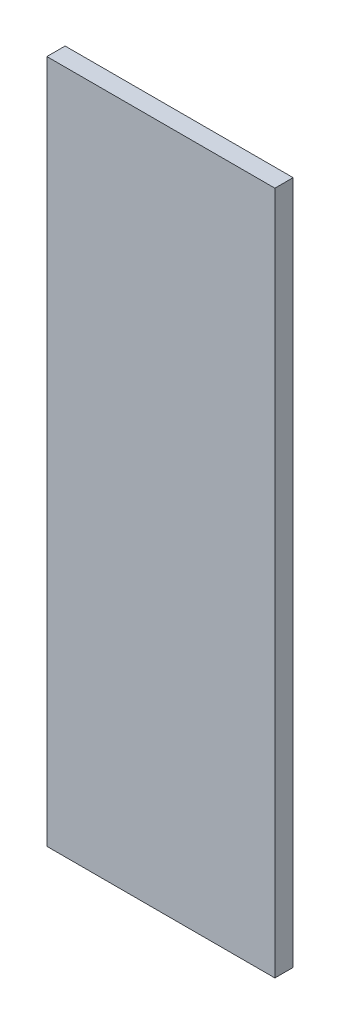
from build123d import *

# Parameters (mm, degrees)
SKETCH1_W           = 50
SKETCH1_H           = 150
BOSS_EXTRUDE1_DEPTH = 4


with BuildPart() as part:
    # Sketch1 → Boss-Extrude1 (new body)
    with BuildSketch(Plane.XY):
        with Locations((25, 75)):
            Rectangle(SKETCH1_W, SKETCH1_H)
    extrude(amount=BOSS_EXTRUDE1_DEPTH)


solid = part.part
